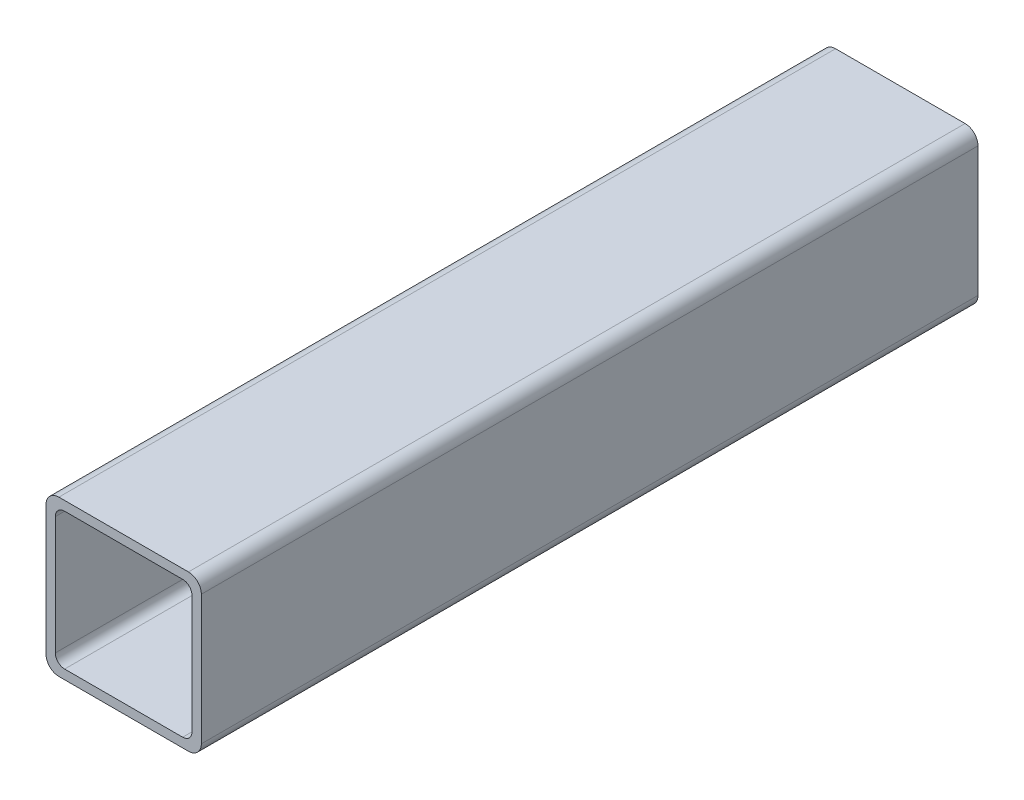
from build123d import *

# Parameters (mm, degrees)
BOSS_EXTRUDE1_DEPTH = 127


with BuildPart() as part:
    # Sketch1 → Boss-Extrude1 (new body)
    with BuildSketch(Plane(origin=(0, 0, -3683), x_dir=(-1, 0, 0), z_dir=(0, 0, -1))):
        with BuildLine():
            Line((12.7, -10.5918), (12.7, 10.5918))
            ThreePointArc((12.7, 10.5918), (12.082522516, 12.082522516), (10.5918, 12.7))
            Line((10.5918, 12.7), (-10.5918, 12.7))
            ThreePointArc((-10.5918, 12.7), (-12.082522516, 12.082522516), (-12.7, 10.5918))
            Line((-12.7, 10.5918), (-12.7, -10.5918))
            ThreePointArc((-12.7, -10.5918), (-12.082522516, -12.082522516), (-10.5918, -12.7))
            Line((-10.5918, -12.7), (10.5918, -12.7))
            ThreePointArc((10.5918, -12.7), (12.082522516, -12.082522516), (12.7, -10.5918))
        make_face()
        with BuildLine():
            Line((11.176, 9.652), (11.176, -9.652))
            ThreePointArc((11.176, -9.652), (10.729630735, -10.729630735), (9.652, -11.176))
            Line((9.652, -11.176), (-9.652, -11.176))
            ThreePointArc((-9.652, -11.176), (-10.729630735, -10.729630735), (-11.176, -9.652))
            Line((-11.176, -9.652), (-11.176, 9.652))
            ThreePointArc((-11.176, 9.652), (-10.729630735, 10.729630735), (-9.652, 11.176))
            Line((-9.652, 11.176), (9.652, 11.176))
            ThreePointArc((9.652, 11.176), (10.729630735, 10.729630735), (11.176, 9.652))
        make_face(mode=Mode.SUBTRACT)
    extrude(amount=-BOSS_EXTRUDE1_DEPTH)


solid = part.part
